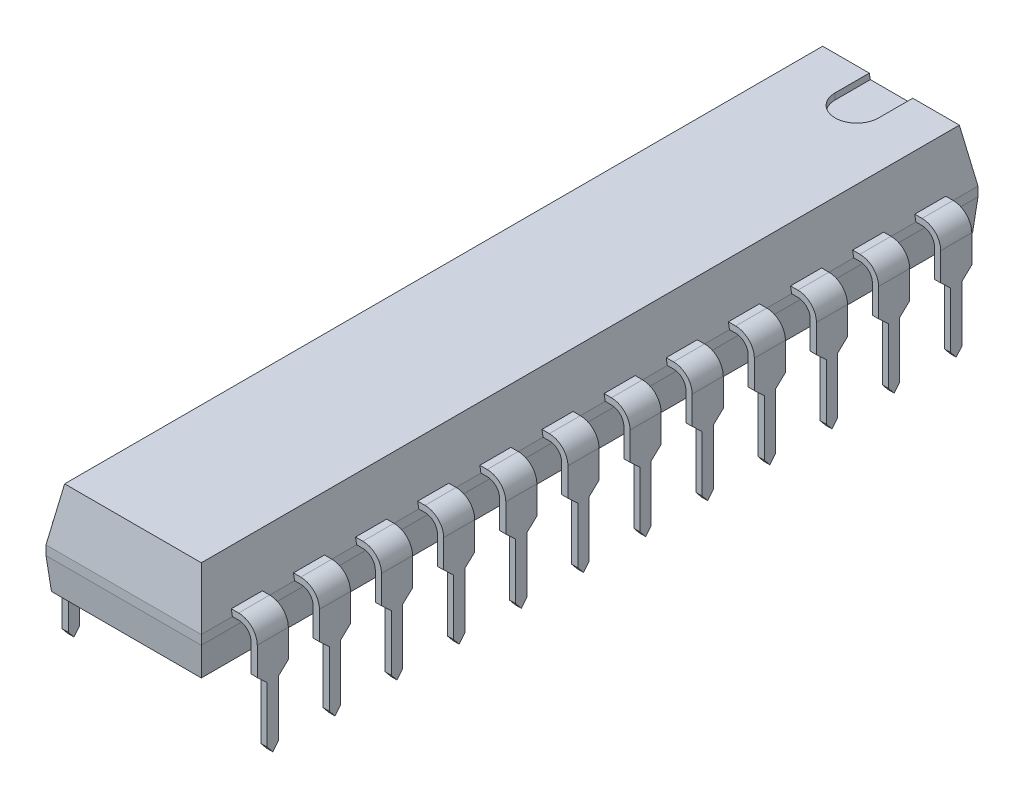
from build123d import *
from OCP.BRepFilletAPI import BRepFilletAPI_MakeChamfer

# Parameters (mm, degrees)
SKETCH2_W                = 31.75
SKETCH2_H                = 6.35
BASE_EXTRUDE_DEPTH       = 3.81
CHAMFER1_SIZE            = 2.159
CHAMFER1_SIZE2           = 0.380689951
CHAMFER2_SIZE            = 1.27
CHAMFER2_SIZE2           = 0.111110603
CUT_EXTRUDE1_DEPTH       = 0.254
BOSS_EXTRUDE_THIN1_DEPTH = 0.635
CUT_EXTRUDE2_DEPTH       = 31.965610764
LPATTERN1_COUNT          = 12
LPATTERN1_PITCH          = 2.54
LPATTERN1_COPY_1_DEPTH   = 31.965610764
LPATTERN1_COPY_2_DEPTH   = 31.965610764
LPATTERN1_COPY_3_DEPTH   = 31.965610764
LPATTERN1_COPY_4_DEPTH   = 31.965610764
LPATTERN1_COPY_5_DEPTH   = 31.965610764
LPATTERN1_COPY_6_DEPTH   = 31.965610764
LPATTERN1_COPY_7_DEPTH   = 31.965610764
LPATTERN1_COPY_8_DEPTH   = 31.965610764
LPATTERN1_COPY_9_DEPTH   = 31.965610764
LPATTERN1_COPY_10_DEPTH  = 31.965610764
LPATTERN1_COPY_11_DEPTH  = 31.965610764
MIRROR2_COPY_1_DEPTH     = 31.965610764
MIRROR2_COPY_2_DEPTH     = 0.635
MIRROR2_COPY_3_DEPTH     = 0.635
MIRROR2_COPY_4_DEPTH     = 0.635
MIRROR2_COPY_5_DEPTH     = 0.635
MIRROR2_COPY_6_DEPTH     = 0.635
MIRROR2_COPY_7_DEPTH     = 0.635
MIRROR2_COPY_8_DEPTH     = 0.635
MIRROR2_COPY_9_DEPTH     = 0.635
MIRROR2_COPY_10_DEPTH    = 0.635
MIRROR2_COPY_11_DEPTH    = 0.635
MIRROR2_COPY_12_DEPTH    = 0.635
MIRROR2_COPY_13_DEPTH    = 31.965610764
MIRROR2_COPY_14_DEPTH    = 31.965610764
MIRROR2_COPY_15_DEPTH    = 31.965610764
MIRROR2_COPY_16_DEPTH    = 31.965610764
MIRROR2_COPY_17_DEPTH    = 31.965610764
MIRROR2_COPY_18_DEPTH    = 31.965610764
MIRROR2_COPY_19_DEPTH    = 31.965610764
MIRROR2_COPY_20_DEPTH    = 31.965610764
MIRROR2_COPY_21_DEPTH    = 31.965610764
MIRROR2_COPY_22_DEPTH    = 31.965610764
MIRROR2_COPY_23_DEPTH    = 31.965610764
MIRROR2_COPY_24_DEPTH    = 31.965610764
MIRROR2_COPY_25_DEPTH    = 31.965610764
MIRROR2_COPY_26_DEPTH    = 31.965610764
MIRROR2_COPY_27_DEPTH    = 31.965610764
MIRROR2_COPY_28_DEPTH    = 31.965610764
MIRROR2_COPY_29_DEPTH    = 31.965610764
MIRROR2_COPY_30_DEPTH    = 31.965610764
MIRROR2_COPY_31_DEPTH    = 31.965610764
MIRROR2_COPY_32_DEPTH    = 31.965610764
MIRROR2_COPY_33_DEPTH    = 31.965610764
MIRROR2_COPY_34_DEPTH    = 31.965610764


with BuildPart() as part:
    # Sketch2 → Base-Extrude (new body)
    with BuildSketch(Plane.ZX.offset(0.381)):
        with Locations((13.97, 3.937)):
            Rectangle(SKETCH2_W, SKETCH2_H)
    extrude(amount=BASE_EXTRUDE_DEPTH)

    # Chamfer1: one chamfer whose edges measure the first distance from different faces: ONE call of the kernel's chamfer builder (chamfer() names one face for all edges)
    chamfer1_edges_1 = [part.edges().sort_by_distance(p)[0] for p in [
        (3.937, 4.191, 29.845),
    ]]
    chamfer1_side_1 = [part.faces().sort_by_distance(p)[0] for p in [
        (3.937, 2.286, 29.845),
    ]]
    chamfer1_edges_2 = [part.edges().sort_by_distance(p)[0] for p in [
        (7.112, 4.191, 13.97),
    ]]
    chamfer1_side_2 = [part.faces().sort_by_distance(p)[0] for p in [
        (7.112, 2.286, 13.97),
    ]]
    chamfer1_edges_3 = [part.edges().sort_by_distance(p)[0] for p in [
        (3.937, 4.191, -1.905),
    ]]
    chamfer1_side_3 = [part.faces().sort_by_distance(p)[0] for p in [
        (3.937, 2.286, -1.905),
    ]]
    chamfer1_edges_4 = [part.edges().sort_by_distance(p)[0] for p in [
        (0.762, 4.191, 13.97),
    ]]
    chamfer1_side_4 = [part.faces().sort_by_distance(p)[0] for p in [
        (0.762, 2.286, 13.97),
    ]]
    chamfer1 = BRepFilletAPI_MakeChamfer(part.part.solid().wrapped)
    for e in chamfer1_edges_1:
        chamfer1.Add(CHAMFER1_SIZE, CHAMFER1_SIZE2, e.wrapped, chamfer1_side_1[0].wrapped)  # the first distance lies on this face
    for e in chamfer1_edges_2:
        chamfer1.Add(CHAMFER1_SIZE, CHAMFER1_SIZE2, e.wrapped, chamfer1_side_2[0].wrapped)  # the first distance lies on this face
    for e in chamfer1_edges_3:
        chamfer1.Add(CHAMFER1_SIZE, CHAMFER1_SIZE2, e.wrapped, chamfer1_side_3[0].wrapped)  # the first distance lies on this face
    for e in chamfer1_edges_4:
        chamfer1.Add(CHAMFER1_SIZE, CHAMFER1_SIZE2, e.wrapped, chamfer1_side_4[0].wrapped)  # the first distance lies on this face
    add(Compound.cast(chamfer1.Shape()), mode=Mode.REPLACE)

    # Chamfer2: one chamfer whose edges measure the first distance from different faces: ONE call of the kernel's chamfer builder (chamfer() names one face for all edges)
    chamfer2_edges_1 = [part.edges().sort_by_distance(p)[0] for p in [
        (7.112, 0.381, 13.97),
    ]]
    chamfer2_side_1 = [part.faces().sort_by_distance(p)[0] for p in [
        (7.112, 1.2065, 13.97),
    ]]
    chamfer2_edges_2 = [part.edges().sort_by_distance(p)[0] for p in [
        (3.937, 0.381, 29.845),
    ]]
    chamfer2_side_2 = [part.faces().sort_by_distance(p)[0] for p in [
        (3.937, 1.2065, 29.845),
    ]]
    chamfer2_edges_3 = [part.edges().sort_by_distance(p)[0] for p in [
        (0.762, 0.381, 13.97),
    ]]
    chamfer2_side_3 = [part.faces().sort_by_distance(p)[0] for p in [
        (0.762, 1.2065, 13.97),
    ]]
    chamfer2_edges_4 = [part.edges().sort_by_distance(p)[0] for p in [
        (3.937, 0.381, -1.905),
    ]]
    chamfer2_side_4 = [part.faces().sort_by_distance(p)[0] for p in [
        (3.937, 1.2065, -1.905),
    ]]
    chamfer2 = BRepFilletAPI_MakeChamfer(part.part.solid().wrapped)
    for e in chamfer2_edges_1:
        chamfer2.Add(CHAMFER2_SIZE, CHAMFER2_SIZE2, e.wrapped, chamfer2_side_1[0].wrapped)  # the first distance lies on this face
    for e in chamfer2_edges_2:
        chamfer2.Add(CHAMFER2_SIZE, CHAMFER2_SIZE2, e.wrapped, chamfer2_side_2[0].wrapped)  # the first distance lies on this face
    for e in chamfer2_edges_3:
        chamfer2.Add(CHAMFER2_SIZE, CHAMFER2_SIZE2, e.wrapped, chamfer2_side_3[0].wrapped)  # the first distance lies on this face
    for e in chamfer2_edges_4:
        chamfer2.Add(CHAMFER2_SIZE, CHAMFER2_SIZE2, e.wrapped, chamfer2_side_4[0].wrapped)  # the first distance lies on this face
    add(Compound.cast(chamfer2.Shape()), mode=Mode.REPLACE)

    # Sketch3 → Cut-Extrude1 (cut)
    with BuildSketch(Plane(origin=(0, 4.191, 0), x_dir=(-1, 0, 0), z_dir=(0, 1, 0))):
        with BuildLine():
            Line((-3.048, -1.905), (-4.826, -1.905))
            Line((-4.826, -1.905), (-4.826, -0.127))
            ThreePointArc((-4.826, -0.127), (-3.937, 0.762), (-3.048, -0.127))
            Line((-3.048, -0.127), (-3.048, -1.905))
        make_face()
    extrude(amount=-CUT_EXTRUDE1_DEPTH, mode=Mode.SUBTRACT)

    # Sketch4 → Boss-Extrude-Thin1 (add, symmetric)
    with BuildSketch(Plane(origin=(0, 0, 0), x_dir=(-1, 0, 0), z_dir=(0, 0, -1))):
        with BuildLine():
            Line((-1.190335108, 2.032), (-0.508, 2.032))
            ThreePointArc((-0.508, 2.032), (-0.148789755, 1.883210245), (0, 1.524))
            Line((0, 1.524), (0, -2.5654))
            Line((0, -2.5654), (0.254, -2.5654))
            Line((0.254, -2.5654), (0.254, 1.524))
            ThreePointArc((0.254, 1.524), (0.030815367, 2.062815367), (-0.508, 2.286))
            Line((-0.508, 2.286), (-1.190335108, 2.286))
            Line((-1.190335108, 2.286), (-1.190335108, 2.032))
        make_face()
    boss_extrude_thin1 = extrude(amount=BOSS_EXTRUDE_THIN1_DEPTH, both=True)

    # Sketch5 → Cut-Extrude2 (cut, through all)
    with BuildSketch(Plane(origin=(0, 0, 0), x_dir=(0, 0, -1), z_dir=(1, 0, 0))):
        Polygon((0, -2.5654), (-0.635, -2.5654), (-0.635, 0.381), (-0.2286, 0), (-0.2286, -2.286), align=None)
    cut_extrude2 = extrude(amount=-CUT_EXTRUDE2_DEPTH, mode=Mode.SUBTRACT)

    # Mirror1: Cut-Extrude2 across plane
    add(cut_extrude2.mirror(Plane.XY), mode=Mode.SUBTRACT)

    # LPattern1: Boss-Extrude-Thin1, Cut-Extrude2 ×12
    with Locations(*[(0, 0, i * LPATTERN1_PITCH) for i in range(1, LPATTERN1_COUNT)]):
        add(boss_extrude_thin1)
        add(cut_extrude2, mode=Mode.SUBTRACT)

    # LPattern1 copy 1 sketch → LPattern1 copy 1 (cut, through all)
    with BuildSketch(Plane(origin=(0, 0, 2.54), x_dir=(0, 0, 1), z_dir=(1, 0, 0))):
        Polygon((0, 2.5654), (-0.635, 2.5654), (-0.635, -0.381), (-0.2286, 0), (-0.2286, 2.286), align=None)
    extrude(amount=-LPATTERN1_COPY_1_DEPTH, mode=Mode.SUBTRACT)

    # LPattern1 copy 2 sketch → LPattern1 copy 2 (cut, through all)
    with BuildSketch(Plane(origin=(0, 0, 5.08), x_dir=(0, 0, 1), z_dir=(1, 0, 0))):
        Polygon((0, 2.5654), (-0.635, 2.5654), (-0.635, -0.381), (-0.2286, 0), (-0.2286, 2.286), align=None)
    extrude(amount=-LPATTERN1_COPY_2_DEPTH, mode=Mode.SUBTRACT)

    # LPattern1 copy 3 sketch → LPattern1 copy 3 (cut, through all)
    with BuildSketch(Plane(origin=(0, 0, 7.62), x_dir=(0, 0, 1), z_dir=(1, 0, 0))):
        Polygon((0, 2.5654), (-0.635, 2.5654), (-0.635, -0.381), (-0.2286, 0), (-0.2286, 2.286), align=None)
    extrude(amount=-LPATTERN1_COPY_3_DEPTH, mode=Mode.SUBTRACT)

    # LPattern1 copy 4 sketch → LPattern1 copy 4 (cut, through all)
    with BuildSketch(Plane(origin=(0, 0, 10.16), x_dir=(0, 0, 1), z_dir=(1, 0, 0))):
        Polygon((0, 2.5654), (-0.635, 2.5654), (-0.635, -0.381), (-0.2286, 0), (-0.2286, 2.286), align=None)
    extrude(amount=-LPATTERN1_COPY_4_DEPTH, mode=Mode.SUBTRACT)

    # LPattern1 copy 5 sketch → LPattern1 copy 5 (cut, through all)
    with BuildSketch(Plane(origin=(0, 0, 12.7), x_dir=(0, 0, 1), z_dir=(1, 0, 0))):
        Polygon((0, 2.5654), (-0.635, 2.5654), (-0.635, -0.381), (-0.2286, 0), (-0.2286, 2.286), align=None)
    extrude(amount=-LPATTERN1_COPY_5_DEPTH, mode=Mode.SUBTRACT)

    # LPattern1 copy 6 sketch → LPattern1 copy 6 (cut, through all)
    with BuildSketch(Plane(origin=(0, 0, 15.24), x_dir=(0, 0, 1), z_dir=(1, 0, 0))):
        Polygon((0, 2.5654), (-0.635, 2.5654), (-0.635, -0.381), (-0.2286, 0), (-0.2286, 2.286), align=None)
    extrude(amount=-LPATTERN1_COPY_6_DEPTH, mode=Mode.SUBTRACT)

    # LPattern1 copy 7 sketch → LPattern1 copy 7 (cut, through all)
    with BuildSketch(Plane(origin=(0, 0, 17.78), x_dir=(0, 0, 1), z_dir=(1, 0, 0))):
        Polygon((0, 2.5654), (-0.635, 2.5654), (-0.635, -0.381), (-0.2286, 0), (-0.2286, 2.286), align=None)
    extrude(amount=-LPATTERN1_COPY_7_DEPTH, mode=Mode.SUBTRACT)

    # LPattern1 copy 8 sketch → LPattern1 copy 8 (cut, through all)
    with BuildSketch(Plane(origin=(0, 0, 20.32), x_dir=(0, 0, 1), z_dir=(1, 0, 0))):
        Polygon((0, 2.5654), (-0.635, 2.5654), (-0.635, -0.381), (-0.2286, 0), (-0.2286, 2.286), align=None)
    extrude(amount=-LPATTERN1_COPY_8_DEPTH, mode=Mode.SUBTRACT)

    # LPattern1 copy 9 sketch → LPattern1 copy 9 (cut, through all)
    with BuildSketch(Plane(origin=(0, 0, 22.86), x_dir=(0, 0, 1), z_dir=(1, 0, 0))):
        Polygon((0, 2.5654), (-0.635, 2.5654), (-0.635, -0.381), (-0.2286, 0), (-0.2286, 2.286), align=None)
    extrude(amount=-LPATTERN1_COPY_9_DEPTH, mode=Mode.SUBTRACT)

    # LPattern1 copy 10 sketch → LPattern1 copy 10 (cut, through all)
    with BuildSketch(Plane(origin=(0, 0, 25.4), x_dir=(0, 0, 1), z_dir=(1, 0, 0))):
        Polygon((0, 2.5654), (-0.635, 2.5654), (-0.635, -0.381), (-0.2286, 0), (-0.2286, 2.286), align=None)
    extrude(amount=-LPATTERN1_COPY_10_DEPTH, mode=Mode.SUBTRACT)

    # LPattern1 copy 11 sketch → LPattern1 copy 11 (cut, through all)
    with BuildSketch(Plane(origin=(0, 0, 27.94), x_dir=(0, 0, 1), z_dir=(1, 0, 0))):
        Polygon((0, 2.5654), (-0.635, 2.5654), (-0.635, -0.381), (-0.2286, 0), (-0.2286, 2.286), align=None)
    extrude(amount=-LPATTERN1_COPY_11_DEPTH, mode=Mode.SUBTRACT)

    # Mirror2: Boss-Extrude-Thin1, Cut-Extrude2 across plane
    add(boss_extrude_thin1.mirror(Plane.ZY.offset(-3.937)))
    add(cut_extrude2.mirror(Plane.ZY.offset(-3.937)), mode=Mode.SUBTRACT)

    # Mirror2 copy 1 sketch → Mirror2 copy 1 (cut, through all)
    with BuildSketch(Plane.ZY.offset(-7.874)):
        Polygon((0, -2.5654), (-0.635, -2.5654), (-0.635, 0.381), (-0.2286, 0), (-0.2286, -2.286), align=None)
    extrude(amount=-MIRROR2_COPY_1_DEPTH, mode=Mode.SUBTRACT)

    # Mirror2 copy 2 sketch → Mirror2 copy 2 (add, symmetric)
    with BuildSketch(Plane(origin=(7.874, 0, 2.54), x_dir=(1, 0, 0), z_dir=(0, 0, -1))):
        with BuildLine():
            Line((-1.190335108, -2.032), (-0.508, -2.032))
            ThreePointArc((-0.508, -2.032), (-0.148789755, -1.883210245), (0, -1.524))
            Line((0, -1.524), (0, 2.5654))
            Line((0, 2.5654), (0.254, 2.5654))
            Line((0.254, 2.5654), (0.254, -1.524))
            ThreePointArc((0.254, -1.524), (0.030815367, -2.062815367), (-0.508, -2.286))
            Line((-0.508, -2.286), (-1.190335108, -2.286))
            Line((-1.190335108, -2.286), (-1.190335108, -2.032))
        make_face()
    extrude(amount=MIRROR2_COPY_2_DEPTH, both=True)

    # Mirror2 copy 3 sketch → Mirror2 copy 3 (add, symmetric)
    with BuildSketch(Plane(origin=(7.874, 0, 5.08), x_dir=(1, 0, 0), z_dir=(0, 0, -1))):
        with BuildLine():
            Line((-1.190335108, -2.032), (-0.508, -2.032))
            ThreePointArc((-0.508, -2.032), (-0.148789755, -1.883210245), (0, -1.524))
            Line((0, -1.524), (0, 2.5654))
            Line((0, 2.5654), (0.254, 2.5654))
            Line((0.254, 2.5654), (0.254, -1.524))
            ThreePointArc((0.254, -1.524), (0.030815367, -2.062815367), (-0.508, -2.286))
            Line((-0.508, -2.286), (-1.190335108, -2.286))
            Line((-1.190335108, -2.286), (-1.190335108, -2.032))
        make_face()
    extrude(amount=MIRROR2_COPY_3_DEPTH, both=True)

    # Mirror2 copy 4 sketch → Mirror2 copy 4 (add, symmetric)
    with BuildSketch(Plane(origin=(7.874, 0, 7.62), x_dir=(1, 0, 0), z_dir=(0, 0, -1))):
        with BuildLine():
            Line((-1.190335108, -2.032), (-0.508, -2.032))
            ThreePointArc((-0.508, -2.032), (-0.148789755, -1.883210245), (0, -1.524))
            Line((0, -1.524), (0, 2.5654))
            Line((0, 2.5654), (0.254, 2.5654))
            Line((0.254, 2.5654), (0.254, -1.524))
            ThreePointArc((0.254, -1.524), (0.030815367, -2.062815367), (-0.508, -2.286))
            Line((-0.508, -2.286), (-1.190335108, -2.286))
            Line((-1.190335108, -2.286), (-1.190335108, -2.032))
        make_face()
    extrude(amount=MIRROR2_COPY_4_DEPTH, both=True)

    # Mirror2 copy 5 sketch → Mirror2 copy 5 (add, symmetric)
    with BuildSketch(Plane(origin=(7.874, 0, 10.16), x_dir=(1, 0, 0), z_dir=(0, 0, -1))):
        with BuildLine():
            Line((-1.190335108, -2.032), (-0.508, -2.032))
            ThreePointArc((-0.508, -2.032), (-0.148789755, -1.883210245), (0, -1.524))
            Line((0, -1.524), (0, 2.5654))
            Line((0, 2.5654), (0.254, 2.5654))
            Line((0.254, 2.5654), (0.254, -1.524))
            ThreePointArc((0.254, -1.524), (0.030815367, -2.062815367), (-0.508, -2.286))
            Line((-0.508, -2.286), (-1.190335108, -2.286))
            Line((-1.190335108, -2.286), (-1.190335108, -2.032))
        make_face()
    extrude(amount=MIRROR2_COPY_5_DEPTH, both=True)

    # Mirror2 copy 6 sketch → Mirror2 copy 6 (add, symmetric)
    with BuildSketch(Plane(origin=(7.874, 0, 12.7), x_dir=(1, 0, 0), z_dir=(0, 0, -1))):
        with BuildLine():
            Line((-1.190335108, -2.032), (-0.508, -2.032))
            ThreePointArc((-0.508, -2.032), (-0.148789755, -1.883210245), (0, -1.524))
            Line((0, -1.524), (0, 2.5654))
            Line((0, 2.5654), (0.254, 2.5654))
            Line((0.254, 2.5654), (0.254, -1.524))
            ThreePointArc((0.254, -1.524), (0.030815367, -2.062815367), (-0.508, -2.286))
            Line((-0.508, -2.286), (-1.190335108, -2.286))
            Line((-1.190335108, -2.286), (-1.190335108, -2.032))
        make_face()
    extrude(amount=MIRROR2_COPY_6_DEPTH, both=True)

    # Mirror2 copy 7 sketch → Mirror2 copy 7 (add, symmetric)
    with BuildSketch(Plane(origin=(7.874, 0, 15.24), x_dir=(1, 0, 0), z_dir=(0, 0, -1))):
        with BuildLine():
            Line((-1.190335108, -2.032), (-0.508, -2.032))
            ThreePointArc((-0.508, -2.032), (-0.148789755, -1.883210245), (0, -1.524))
            Line((0, -1.524), (0, 2.5654))
            Line((0, 2.5654), (0.254, 2.5654))
            Line((0.254, 2.5654), (0.254, -1.524))
            ThreePointArc((0.254, -1.524), (0.030815367, -2.062815367), (-0.508, -2.286))
            Line((-0.508, -2.286), (-1.190335108, -2.286))
            Line((-1.190335108, -2.286), (-1.190335108, -2.032))
        make_face()
    extrude(amount=MIRROR2_COPY_7_DEPTH, both=True)

    # Mirror2 copy 8 sketch → Mirror2 copy 8 (add, symmetric)
    with BuildSketch(Plane(origin=(7.874, 0, 17.78), x_dir=(1, 0, 0), z_dir=(0, 0, -1))):
        with BuildLine():
            Line((-1.190335108, -2.032), (-0.508, -2.032))
            ThreePointArc((-0.508, -2.032), (-0.148789755, -1.883210245), (0, -1.524))
            Line((0, -1.524), (0, 2.5654))
            Line((0, 2.5654), (0.254, 2.5654))
            Line((0.254, 2.5654), (0.254, -1.524))
            ThreePointArc((0.254, -1.524), (0.030815367, -2.062815367), (-0.508, -2.286))
            Line((-0.508, -2.286), (-1.190335108, -2.286))
            Line((-1.190335108, -2.286), (-1.190335108, -2.032))
        make_face()
    extrude(amount=MIRROR2_COPY_8_DEPTH, both=True)

    # Mirror2 copy 9 sketch → Mirror2 copy 9 (add, symmetric)
    with BuildSketch(Plane(origin=(7.874, 0, 20.32), x_dir=(1, 0, 0), z_dir=(0, 0, -1))):
        with BuildLine():
            Line((-1.190335108, -2.032), (-0.508, -2.032))
            ThreePointArc((-0.508, -2.032), (-0.148789755, -1.883210245), (0, -1.524))
            Line((0, -1.524), (0, 2.5654))
            Line((0, 2.5654), (0.254, 2.5654))
            Line((0.254, 2.5654), (0.254, -1.524))
            ThreePointArc((0.254, -1.524), (0.030815367, -2.062815367), (-0.508, -2.286))
            Line((-0.508, -2.286), (-1.190335108, -2.286))
            Line((-1.190335108, -2.286), (-1.190335108, -2.032))
        make_face()
    extrude(amount=MIRROR2_COPY_9_DEPTH, both=True)

    # Mirror2 copy 10 sketch → Mirror2 copy 10 (add, symmetric)
    with BuildSketch(Plane(origin=(7.874, 0, 22.86), x_dir=(1, 0, 0), z_dir=(0, 0, -1))):
        with BuildLine():
            Line((-1.190335108, -2.032), (-0.508, -2.032))
            ThreePointArc((-0.508, -2.032), (-0.148789755, -1.883210245), (0, -1.524))
            Line((0, -1.524), (0, 2.5654))
            Line((0, 2.5654), (0.254, 2.5654))
            Line((0.254, 2.5654), (0.254, -1.524))
            ThreePointArc((0.254, -1.524), (0.030815367, -2.062815367), (-0.508, -2.286))
            Line((-0.508, -2.286), (-1.190335108, -2.286))
            Line((-1.190335108, -2.286), (-1.190335108, -2.032))
        make_face()
    extrude(amount=MIRROR2_COPY_10_DEPTH, both=True)

    # Mirror2 copy 11 sketch → Mirror2 copy 11 (add, symmetric)
    with BuildSketch(Plane(origin=(7.874, 0, 25.4), x_dir=(1, 0, 0), z_dir=(0, 0, -1))):
        with BuildLine():
            Line((-1.190335108, -2.032), (-0.508, -2.032))
            ThreePointArc((-0.508, -2.032), (-0.148789755, -1.883210245), (0, -1.524))
            Line((0, -1.524), (0, 2.5654))
            Line((0, 2.5654), (0.254, 2.5654))
            Line((0.254, 2.5654), (0.254, -1.524))
            ThreePointArc((0.254, -1.524), (0.030815367, -2.062815367), (-0.508, -2.286))
            Line((-0.508, -2.286), (-1.190335108, -2.286))
            Line((-1.190335108, -2.286), (-1.190335108, -2.032))
        make_face()
    extrude(amount=MIRROR2_COPY_11_DEPTH, both=True)

    # Mirror2 copy 12 sketch → Mirror2 copy 12 (add, symmetric)
    with BuildSketch(Plane(origin=(7.874, 0, 27.94), x_dir=(1, 0, 0), z_dir=(0, 0, -1))):
        with BuildLine():
            Line((-1.190335108, -2.032), (-0.508, -2.032))
            ThreePointArc((-0.508, -2.032), (-0.148789755, -1.883210245), (0, -1.524))
            Line((0, -1.524), (0, 2.5654))
            Line((0, 2.5654), (0.254, 2.5654))
            Line((0.254, 2.5654), (0.254, -1.524))
            ThreePointArc((0.254, -1.524), (0.030815367, -2.062815367), (-0.508, -2.286))
            Line((-0.508, -2.286), (-1.190335108, -2.286))
            Line((-1.190335108, -2.286), (-1.190335108, -2.032))
        make_face()
    extrude(amount=MIRROR2_COPY_12_DEPTH, both=True)

    # Mirror2 copy 13 sketch → Mirror2 copy 13 (cut, through all)
    with BuildSketch(Plane(origin=(7.874, 0, 2.54), x_dir=(0, 0, -1), z_dir=(-1, 0, 0))):
        Polygon((0, 2.5654), (-0.635, 2.5654), (-0.635, -0.381), (-0.2286, 0), (-0.2286, 2.286), align=None)
    extrude(amount=-MIRROR2_COPY_13_DEPTH, mode=Mode.SUBTRACT)

    # Mirror2 copy 14 sketch → Mirror2 copy 14 (cut, through all)
    with BuildSketch(Plane(origin=(7.874, 0, 5.08), x_dir=(0, 0, -1), z_dir=(-1, 0, 0))):
        Polygon((0, 2.5654), (-0.635, 2.5654), (-0.635, -0.381), (-0.2286, 0), (-0.2286, 2.286), align=None)
    extrude(amount=-MIRROR2_COPY_14_DEPTH, mode=Mode.SUBTRACT)

    # Mirror2 copy 15 sketch → Mirror2 copy 15 (cut, through all)
    with BuildSketch(Plane(origin=(7.874, 0, 7.62), x_dir=(0, 0, -1), z_dir=(-1, 0, 0))):
        Polygon((0, 2.5654), (-0.635, 2.5654), (-0.635, -0.381), (-0.2286, 0), (-0.2286, 2.286), align=None)
    extrude(amount=-MIRROR2_COPY_15_DEPTH, mode=Mode.SUBTRACT)

    # Mirror2 copy 16 sketch → Mirror2 copy 16 (cut, through all)
    with BuildSketch(Plane(origin=(7.874, 0, 10.16), x_dir=(0, 0, -1), z_dir=(-1, 0, 0))):
        Polygon((0, 2.5654), (-0.635, 2.5654), (-0.635, -0.381), (-0.2286, 0), (-0.2286, 2.286), align=None)
    extrude(amount=-MIRROR2_COPY_16_DEPTH, mode=Mode.SUBTRACT)

    # Mirror2 copy 17 sketch → Mirror2 copy 17 (cut, through all)
    with BuildSketch(Plane(origin=(7.874, 0, 12.7), x_dir=(0, 0, -1), z_dir=(-1, 0, 0))):
        Polygon((0, 2.5654), (-0.635, 2.5654), (-0.635, -0.381), (-0.2286, 0), (-0.2286, 2.286), align=None)
    extrude(amount=-MIRROR2_COPY_17_DEPTH, mode=Mode.SUBTRACT)

    # Mirror2 copy 18 sketch → Mirror2 copy 18 (cut, through all)
    with BuildSketch(Plane(origin=(7.874, 0, 15.24), x_dir=(0, 0, -1), z_dir=(-1, 0, 0))):
        Polygon((0, 2.5654), (-0.635, 2.5654), (-0.635, -0.381), (-0.2286, 0), (-0.2286, 2.286), align=None)
    extrude(amount=-MIRROR2_COPY_18_DEPTH, mode=Mode.SUBTRACT)

    # Mirror2 copy 19 sketch → Mirror2 copy 19 (cut, through all)
    with BuildSketch(Plane(origin=(7.874, 0, 17.78), x_dir=(0, 0, -1), z_dir=(-1, 0, 0))):
        Polygon((0, 2.5654), (-0.635, 2.5654), (-0.635, -0.381), (-0.2286, 0), (-0.2286, 2.286), align=None)
    extrude(amount=-MIRROR2_COPY_19_DEPTH, mode=Mode.SUBTRACT)

    # Mirror2 copy 20 sketch → Mirror2 copy 20 (cut, through all)
    with BuildSketch(Plane(origin=(7.874, 0, 20.32), x_dir=(0, 0, -1), z_dir=(-1, 0, 0))):
        Polygon((0, 2.5654), (-0.635, 2.5654), (-0.635, -0.381), (-0.2286, 0), (-0.2286, 2.286), align=None)
    extrude(amount=-MIRROR2_COPY_20_DEPTH, mode=Mode.SUBTRACT)

    # Mirror2 copy 21 sketch → Mirror2 copy 21 (cut, through all)
    with BuildSketch(Plane(origin=(7.874, 0, 22.86), x_dir=(0, 0, -1), z_dir=(-1, 0, 0))):
        Polygon((0, 2.5654), (-0.635, 2.5654), (-0.635, -0.381), (-0.2286, 0), (-0.2286, 2.286), align=None)
    extrude(amount=-MIRROR2_COPY_21_DEPTH, mode=Mode.SUBTRACT)

    # Mirror2 copy 22 sketch → Mirror2 copy 22 (cut, through all)
    with BuildSketch(Plane(origin=(7.874, 0, 25.4), x_dir=(0, 0, -1), z_dir=(-1, 0, 0))):
        Polygon((0, 2.5654), (-0.635, 2.5654), (-0.635, -0.381), (-0.2286, 0), (-0.2286, 2.286), align=None)
    extrude(amount=-MIRROR2_COPY_22_DEPTH, mode=Mode.SUBTRACT)

    # Mirror2 copy 23 sketch → Mirror2 copy 23 (cut, through all)
    with BuildSketch(Plane(origin=(7.874, 0, 27.94), x_dir=(0, 0, -1), z_dir=(-1, 0, 0))):
        Polygon((0, 2.5654), (-0.635, 2.5654), (-0.635, -0.381), (-0.2286, 0), (-0.2286, 2.286), align=None)
    extrude(amount=-MIRROR2_COPY_23_DEPTH, mode=Mode.SUBTRACT)

    # Mirror2 copy 24 sketch → Mirror2 copy 24 (cut, through all)
    with BuildSketch(Plane(origin=(7.874, 0, 2.54), x_dir=(0, 0, 1), z_dir=(-1, 0, 0))):
        Polygon((0, -2.5654), (-0.635, -2.5654), (-0.635, 0.381), (-0.2286, 0), (-0.2286, -2.286), align=None)
    extrude(amount=-MIRROR2_COPY_24_DEPTH, mode=Mode.SUBTRACT)

    # Mirror2 copy 25 sketch → Mirror2 copy 25 (cut, through all)
    with BuildSketch(Plane(origin=(7.874, 0, 5.08), x_dir=(0, 0, 1), z_dir=(-1, 0, 0))):
        Polygon((0, -2.5654), (-0.635, -2.5654), (-0.635, 0.381), (-0.2286, 0), (-0.2286, -2.286), align=None)
    extrude(amount=-MIRROR2_COPY_25_DEPTH, mode=Mode.SUBTRACT)

    # Mirror2 copy 26 sketch → Mirror2 copy 26 (cut, through all)
    with BuildSketch(Plane(origin=(7.874, 0, 7.62), x_dir=(0, 0, 1), z_dir=(-1, 0, 0))):
        Polygon((0, -2.5654), (-0.635, -2.5654), (-0.635, 0.381), (-0.2286, 0), (-0.2286, -2.286), align=None)
    extrude(amount=-MIRROR2_COPY_26_DEPTH, mode=Mode.SUBTRACT)

    # Mirror2 copy 27 sketch → Mirror2 copy 27 (cut, through all)
    with BuildSketch(Plane(origin=(7.874, 0, 10.16), x_dir=(0, 0, 1), z_dir=(-1, 0, 0))):
        Polygon((0, -2.5654), (-0.635, -2.5654), (-0.635, 0.381), (-0.2286, 0), (-0.2286, -2.286), align=None)
    extrude(amount=-MIRROR2_COPY_27_DEPTH, mode=Mode.SUBTRACT)

    # Mirror2 copy 28 sketch → Mirror2 copy 28 (cut, through all)
    with BuildSketch(Plane(origin=(7.874, 0, 12.7), x_dir=(0, 0, 1), z_dir=(-1, 0, 0))):
        Polygon((0, -2.5654), (-0.635, -2.5654), (-0.635, 0.381), (-0.2286, 0), (-0.2286, -2.286), align=None)
    extrude(amount=-MIRROR2_COPY_28_DEPTH, mode=Mode.SUBTRACT)

    # Mirror2 copy 29 sketch → Mirror2 copy 29 (cut, through all)
    with BuildSketch(Plane(origin=(7.874, 0, 15.24), x_dir=(0, 0, 1), z_dir=(-1, 0, 0))):
        Polygon((0, -2.5654), (-0.635, -2.5654), (-0.635, 0.381), (-0.2286, 0), (-0.2286, -2.286), align=None)
    extrude(amount=-MIRROR2_COPY_29_DEPTH, mode=Mode.SUBTRACT)

    # Mirror2 copy 30 sketch → Mirror2 copy 30 (cut, through all)
    with BuildSketch(Plane(origin=(7.874, 0, 17.78), x_dir=(0, 0, 1), z_dir=(-1, 0, 0))):
        Polygon((0, -2.5654), (-0.635, -2.5654), (-0.635, 0.381), (-0.2286, 0), (-0.2286, -2.286), align=None)
    extrude(amount=-MIRROR2_COPY_30_DEPTH, mode=Mode.SUBTRACT)

    # Mirror2 copy 31 sketch → Mirror2 copy 31 (cut, through all)
    with BuildSketch(Plane(origin=(7.874, 0, 20.32), x_dir=(0, 0, 1), z_dir=(-1, 0, 0))):
        Polygon((0, -2.5654), (-0.635, -2.5654), (-0.635, 0.381), (-0.2286, 0), (-0.2286, -2.286), align=None)
    extrude(amount=-MIRROR2_COPY_31_DEPTH, mode=Mode.SUBTRACT)

    # Mirror2 copy 32 sketch → Mirror2 copy 32 (cut, through all)
    with BuildSketch(Plane(origin=(7.874, 0, 22.86), x_dir=(0, 0, 1), z_dir=(-1, 0, 0))):
        Polygon((0, -2.5654), (-0.635, -2.5654), (-0.635, 0.381), (-0.2286, 0), (-0.2286, -2.286), align=None)
    extrude(amount=-MIRROR2_COPY_32_DEPTH, mode=Mode.SUBTRACT)

    # Mirror2 copy 33 sketch → Mirror2 copy 33 (cut, through all)
    with BuildSketch(Plane(origin=(7.874, 0, 25.4), x_dir=(0, 0, 1), z_dir=(-1, 0, 0))):
        Polygon((0, -2.5654), (-0.635, -2.5654), (-0.635, 0.381), (-0.2286, 0), (-0.2286, -2.286), align=None)
    extrude(amount=-MIRROR2_COPY_33_DEPTH, mode=Mode.SUBTRACT)

    # Mirror2 copy 34 sketch → Mirror2 copy 34 (cut, through all)
    with BuildSketch(Plane(origin=(7.874, 0, 27.94), x_dir=(0, 0, 1), z_dir=(-1, 0, 0))):
        Polygon((0, -2.5654), (-0.635, -2.5654), (-0.635, 0.381), (-0.2286, 0), (-0.2286, -2.286), align=None)
    extrude(amount=-MIRROR2_COPY_34_DEPTH, mode=Mode.SUBTRACT)


solid = part.part
